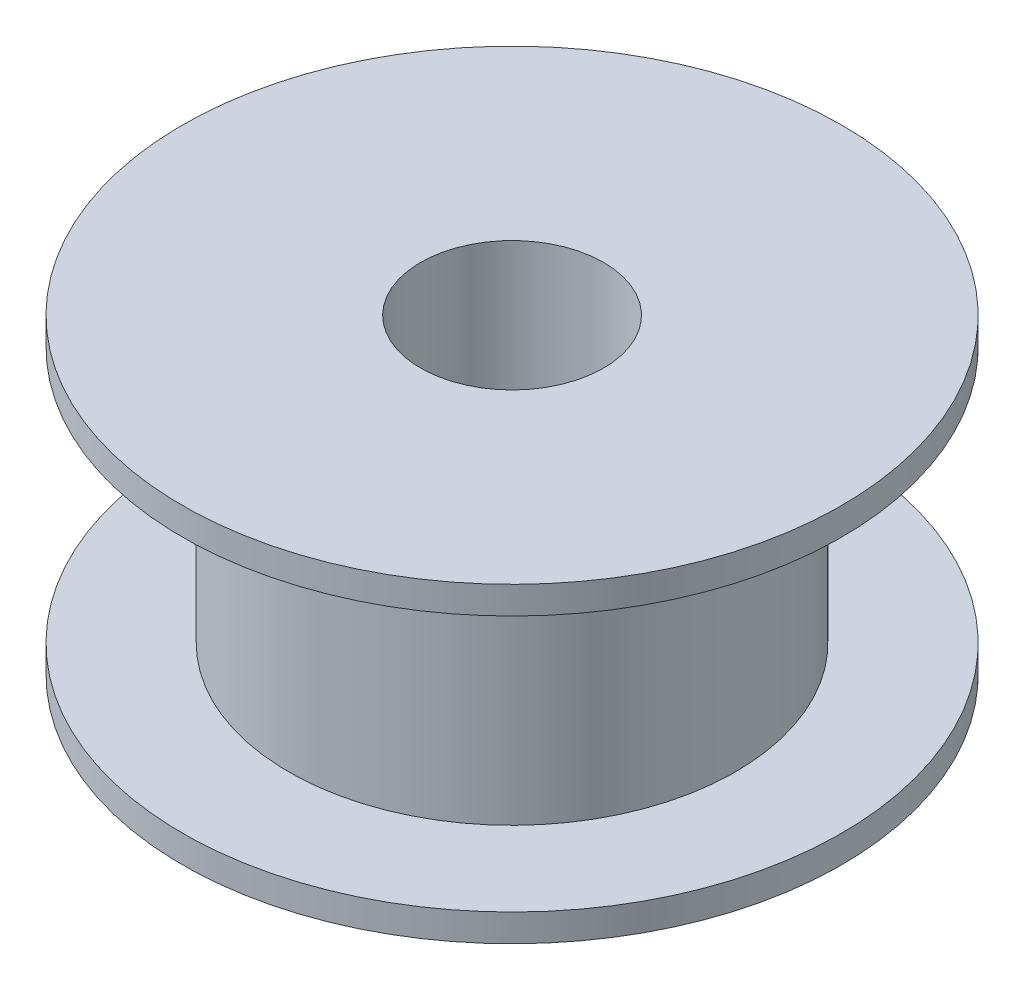
from build123d import *


with BuildPart() as part:
    # Sketch1 → Revolve1 (revolve)
    with BuildSketch(Plane.XY):
        Polygon((2.5, 0), (2.5, 8.5), (9, 8.5), (9, 7.75), (6.1, 7.75), (6.1, 0.75), (9, 0.75), (9, 0), align=None)
    revolve(axis=Axis((0, 0, 0), (0, 1, 0)))


solid = part.part
